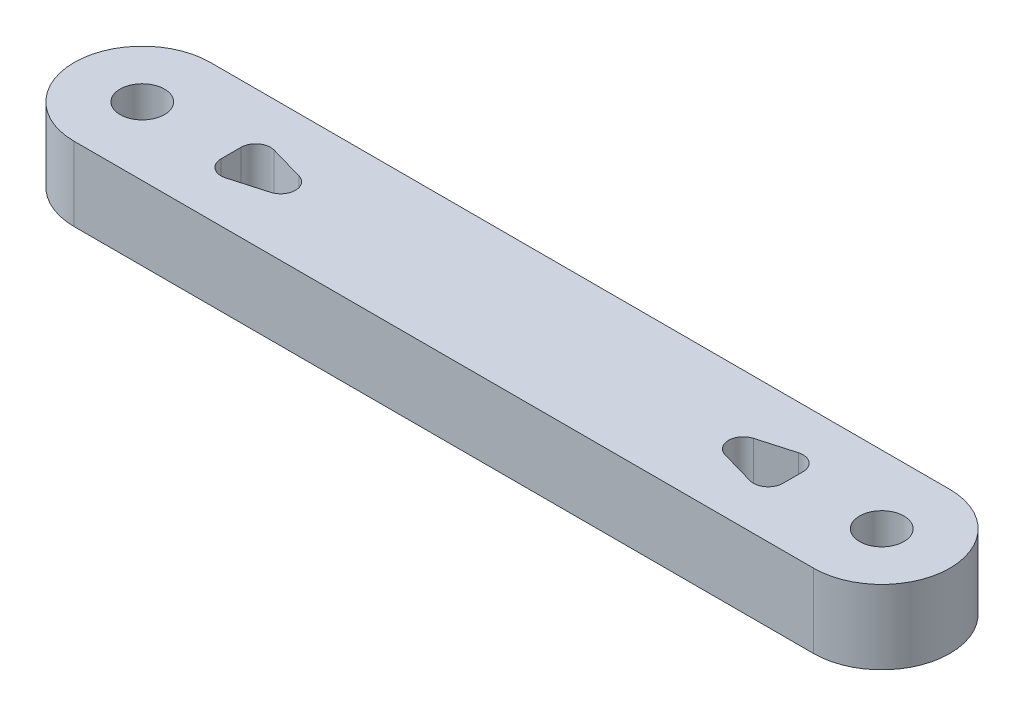
from build123d import *

# Parameters (mm, degrees)
SKETCH1_R           = 1.5
BOSS_EXTRUDE1_DEPTH = 5
CUT_EXTRUDE2_DEPTH  = 17
FILLET1_R           = 1


with BuildPart() as part:
    # Sketch1 → Boss-Extrude1 (new body)
    with BuildSketch(Plane(origin=(0, 0, 0), x_dir=(1, 0, 0), z_dir=(0, 1, 0))):
        with BuildLine():
            Line((0, 4.610590887), (50, 4.610590887))
            ThreePointArc((50, 4.610590887), (54.610590887, 0), (50, -4.610590887))
            Line((50, -4.610590887), (0, -4.610590887))
            ThreePointArc((0, -4.610590887), (-4.610590887, 0), (0, 4.610590887))
        make_face()
        Circle(SKETCH1_R, mode=Mode.SUBTRACT)
        with Locations((50, 0)):
            Circle(SKETCH1_R, mode=Mode.SUBTRACT)
    extrude(amount=BOSS_EXTRUDE1_DEPTH)

    # Sketch3 → Cut-Extrude2 (cut)
    with BuildSketch(Plane(origin=(0, 5, 0), x_dir=(1, 0, 0), z_dir=(0, 1, 0))):
        Polygon((6, 2), (6, -2), (13, 0), align=None)
        Polygon((44, 2), (44, -2), (37, 0), align=None)
    extrude(amount=-CUT_EXTRUDE2_DEPTH, mode=Mode.SUBTRACT)

    # Fillet1
    fillet1_edges = [part.edges().sort_by_distance(p)[0] for p in [
        (6, 2.5, -2),
        (13, 2.5, 0),
        (6, 2.5, 2),
        (37, 2.5, 0),
        (44, 2.5, -2),
        (44, 2.5, 2),
    ]]
    fillet(fillet1_edges, radius=FILLET1_R)


solid = part.part
